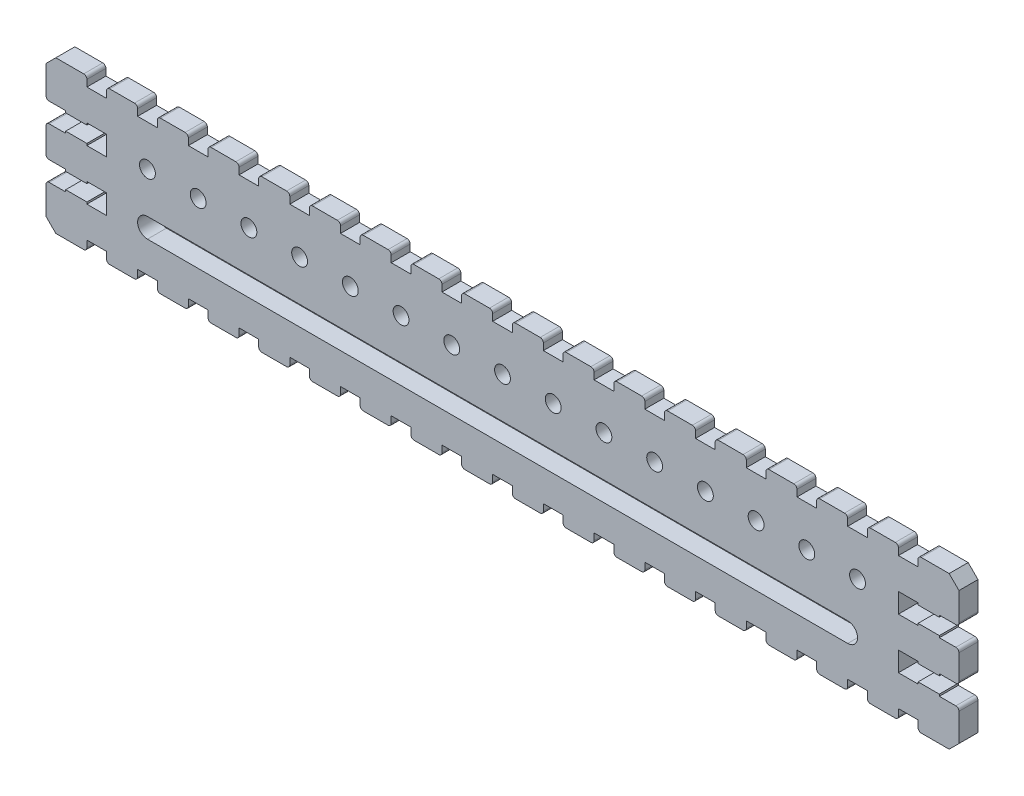
from build123d import *

# Parameters (mm, degrees)
SKETCH_1_R      = 1.25
EXTRUDE_1_DEPTH = 3


with BuildPart() as part:
    # 草图1 → 凸台-拉伸1 (new body)
    with BuildSketch(Plane.XY):
        with BuildLine():
            Line((8.341212166, 48.379842569), (12.741212166, 48.379842569))
            ThreePointArc((12.741212166, 48.379842569), (13.094765557, 48.23339596), (13.241212166, 47.879842569))
            Line((13.241212166, 47.879842569), (13.241212166, 46.829842569))
            Line((13.241212166, 46.829842569), (16.341212166, 46.829842569))
            Line((16.341212166, 46.829842569), (16.341212166, 47.879842569))
            ThreePointArc((16.341212166, 47.879842569), (16.487658775, 48.23339596), (16.841212166, 48.379842569))
            Line((16.841212166, 48.379842569), (20.741212166, 48.379842569))
            ThreePointArc((20.741212166, 48.379842569), (21.094765557, 48.23339596), (21.241212166, 47.879842569))
            Line((21.241212166, 47.879842569), (21.241212166, 46.829842569))
            Line((21.241212166, 46.829842569), (24.341212166, 46.829842569))
            Line((24.341212166, 46.829842569), (24.341212166, 47.879842569))
            ThreePointArc((24.341212166, 47.879842569), (24.487658775, 48.23339596), (24.841212166, 48.379842569))
            Line((24.841212166, 48.379842569), (28.741212166, 48.379842569))
            ThreePointArc((28.741212166, 48.379842569), (29.094765557, 48.23339596), (29.241212166, 47.879842569))
            Line((29.241212166, 47.879842569), (29.241212166, 46.829842569))
            Line((29.241212166, 46.829842569), (32.341212166, 46.829842569))
            Line((32.341212166, 46.829842569), (32.341212166, 47.879842569))
            ThreePointArc((32.341212166, 47.879842569), (32.487658775, 48.23339596), (32.841212166, 48.379842569))
            Line((32.841212166, 48.379842569), (36.741212166, 48.379842569))
            ThreePointArc((36.741212166, 48.379842569), (37.094765557, 48.23339596), (37.241212166, 47.879842569))
            Line((37.241212166, 47.879842569), (37.241212166, 46.829842569))
            Line((37.241212166, 46.829842569), (40.341212166, 46.829842569))
            Line((40.341212166, 46.829842569), (40.341212166, 47.879842569))
            ThreePointArc((40.341212166, 47.879842569), (40.487658775, 48.23339596), (40.841212166, 48.379842569))
            Line((40.841212166, 48.379842569), (44.741212166, 48.379842569))
            ThreePointArc((44.741212166, 48.379842569), (45.094765557, 48.23339596), (45.241212166, 47.879842569))
            Line((45.241212166, 47.879842569), (45.241212166, 46.829842569))
            Line((45.241212166, 46.829842569), (48.341212166, 46.829842569))
            Line((48.341212166, 46.829842569), (48.341212166, 47.879842569))
            ThreePointArc((48.341212166, 47.879842569), (48.487658775, 48.23339596), (48.841212166, 48.379842569))
            Line((48.841212166, 48.379842569), (52.741212166, 48.379842569))
            ThreePointArc((52.741212166, 48.379842569), (53.094765557, 48.23339596), (53.241212166, 47.879842569))
            Line((53.241212166, 47.879842569), (53.241212166, 46.829842569))
            Line((53.241212166, 46.829842569), (56.341212166, 46.829842569))
            Line((56.341212166, 46.829842569), (56.341212166, 47.879842569))
            ThreePointArc((56.341212166, 47.879842569), (56.487658775, 48.23339596), (56.841212166, 48.379842569))
            Line((56.841212166, 48.379842569), (60.741212166, 48.379842569))
            ThreePointArc((60.741212166, 48.379842569), (61.094765557, 48.23339596), (61.241212166, 47.879842569))
            Line((61.241212166, 47.879842569), (61.241212166, 46.829842569))
            Line((61.241212166, 46.829842569), (64.341212166, 46.829842569))
            Line((64.341212166, 46.829842569), (64.341212166, 47.879842569))
            ThreePointArc((64.341212166, 47.879842569), (64.487658775, 48.23339596), (64.841212166, 48.379842569))
            Line((64.841212166, 48.379842569), (68.741212166, 48.379842569))
            ThreePointArc((68.741212166, 48.379842569), (69.094765557, 48.23339596), (69.241212166, 47.879842569))
            Line((69.241212166, 47.879842569), (69.241212166, 46.829842569))
            Line((69.241212166, 46.829842569), (72.341212166, 46.829842569))
            Line((72.341212166, 46.829842569), (72.341212166, 47.879842569))
            ThreePointArc((72.341212166, 47.879842569), (72.487658775, 48.23339596), (72.841212166, 48.379842569))
            Line((72.841212166, 48.379842569), (76.741212166, 48.379842569))
            ThreePointArc((76.741212166, 48.379842569), (77.094765557, 48.23339596), (77.241212166, 47.879842569))
            Line((77.241212166, 47.879842569), (77.241212166, 46.829842569))
            Line((77.241212166, 46.829842569), (80.341212166, 46.829842569))
            Line((80.341212166, 46.829842569), (80.341212166, 47.879842569))
            ThreePointArc((80.341212166, 47.879842569), (80.487658775, 48.23339596), (80.841212166, 48.379842569))
            Line((80.841212166, 48.379842569), (84.741212166, 48.379842569))
            ThreePointArc((84.741212166, 48.379842569), (85.094765557, 48.23339596), (85.241212166, 47.879842569))
            Line((85.241212166, 47.879842569), (85.241212166, 46.829842569))
            Line((85.241212166, 46.829842569), (88.341212166, 46.829842569))
            Line((88.341212166, 46.829842569), (88.341212166, 47.879842569))
            ThreePointArc((88.341212166, 47.879842569), (88.487658775, 48.23339596), (88.841212166, 48.379842569))
            Line((88.841212166, 48.379842569), (92.741212166, 48.379842569))
            ThreePointArc((92.741212166, 48.379842569), (93.094765557, 48.23339596), (93.241212166, 47.879842569))
            Line((93.241212166, 47.879842569), (93.241212166, 46.829842569))
            Line((93.241212166, 46.829842569), (96.341212166, 46.829842569))
            Line((96.341212166, 46.829842569), (96.341212166, 47.879842569))
            ThreePointArc((96.341212166, 47.879842569), (96.487658775, 48.23339596), (96.841212166, 48.379842569))
            Line((96.841212166, 48.379842569), (100.741212166, 48.379842569))
            ThreePointArc((100.741212166, 48.379842569), (101.094765557, 48.23339596), (101.241212166, 47.879842569))
            Line((101.241212166, 47.879842569), (101.241212166, 46.829842569))
            Line((101.241212166, 46.829842569), (104.341212166, 46.829842569))
            Line((104.341212166, 46.829842569), (104.341212166, 47.879842569))
            ThreePointArc((104.341212166, 47.879842569), (104.487658775, 48.23339596), (104.841212166, 48.379842569))
            Line((104.841212166, 48.379842569), (108.741212166, 48.379842569))
            ThreePointArc((108.741212166, 48.379842569), (109.094765557, 48.23339596), (109.241212166, 47.879842569))
            Line((109.241212166, 47.879842569), (109.241212166, 46.829842569))
            Line((109.241212166, 46.829842569), (112.341212166, 46.829842569))
            Line((112.341212166, 46.829842569), (112.341212166, 47.879842569))
            ThreePointArc((112.341212166, 47.879842569), (112.487658775, 48.23339596), (112.841212166, 48.379842569))
            Line((112.841212166, 48.379842569), (116.741212166, 48.379842569))
            ThreePointArc((116.741212166, 48.379842569), (117.094765557, 48.23339596), (117.241212166, 47.879842569))
            Line((117.241212166, 47.879842569), (117.241212166, 46.829842569))
            Line((117.241212166, 46.829842569), (120.341212166, 46.829842569))
            Line((120.341212166, 46.829842569), (120.341212166, 47.879842569))
            ThreePointArc((120.341212166, 47.879842569), (120.487658775, 48.23339596), (120.841212166, 48.379842569))
            Line((120.841212166, 48.379842569), (124.741212166, 48.379842569))
            ThreePointArc((124.741212166, 48.379842569), (125.094765557, 48.23339596), (125.241212166, 47.879842569))
            Line((125.241212166, 47.879842569), (125.241212166, 46.829842569))
            Line((125.241212166, 46.829842569), (128.341212166, 46.829842569))
            Line((128.341212166, 46.829842569), (128.341212166, 47.879842569))
            ThreePointArc((128.341212166, 47.879842569), (128.487658775, 48.23339596), (128.841212166, 48.379842569))
            Line((128.841212166, 48.379842569), (132.741212166, 48.379842569))
            ThreePointArc((132.741212166, 48.379842569), (133.094765557, 48.23339596), (133.241212166, 47.879842569))
            Line((133.241212166, 47.879842569), (133.241212166, 46.829842569))
            Line((133.241212166, 46.829842569), (136.341212166, 46.829842569))
            Line((136.341212166, 46.829842569), (136.341212166, 47.879842569))
            ThreePointArc((136.341212166, 47.879842569), (136.487658775, 48.23339596), (136.841212166, 48.379842569))
            Line((136.841212166, 48.379842569), (140.741212166, 48.379842569))
            ThreePointArc((140.741212166, 48.379842569), (141.094765557, 48.23339596), (141.241212166, 47.879842569))
            Line((141.241212166, 47.879842569), (141.241212166, 46.829842569))
            Line((141.241212166, 46.829842569), (144.341212166, 46.829842569))
            Line((144.341212166, 46.829842569), (144.341212166, 47.879842569))
            ThreePointArc((144.341212166, 47.879842569), (144.487658775, 48.23339596), (144.841212166, 48.379842569))
            Line((144.841212166, 48.379842569), (149.241212166, 48.379842569))
            Line((149.241212166, 48.379842569), (150.791212166, 46.829842569))
            Line((150.791212166, 46.829842569), (150.791212166, 42.429842569))
            ThreePointArc((150.791212166, 42.429842569), (150.644765557, 42.076289178), (150.291212166, 41.929842569))
            Line((150.291212166, 41.929842569), (147.691212166, 41.929842569))
            Line((147.691212166, 41.929842569), (147.691212166, 41.629842569))
            Line((147.691212166, 41.629842569), (144.341212166, 41.629842569))
            Line((144.341212166, 41.629842569), (144.341212166, 41.929842569))
            Line((144.341212166, 41.929842569), (141.241212166, 41.929842569))
            Line((141.241212166, 41.929842569), (141.241212166, 38.829842569))
            Line((141.241212166, 38.829842569), (144.341212166, 38.829842569))
            Line((144.341212166, 38.829842569), (144.341212166, 39.129842569))
            Line((144.341212166, 39.129842569), (147.691212166, 39.129842569))
            Line((147.691212166, 39.129842569), (147.691212166, 38.829842569))
            Line((147.691212166, 38.829842569), (150.291212166, 38.829842569))
            ThreePointArc((150.291212166, 38.829842569), (150.644765557, 38.68339596), (150.791212166, 38.329842569))
            Line((150.791212166, 38.329842569), (150.791212166, 34.429842569))
            ThreePointArc((150.791212166, 34.429842569), (150.644765557, 34.076289178), (150.291212166, 33.929842569))
            Line((150.291212166, 33.929842569), (147.691212166, 33.929842569))
            Line((147.691212166, 33.929842569), (147.691212166, 33.629842569))
            Line((147.691212166, 33.629842569), (144.341212166, 33.629842569))
            Line((144.341212166, 33.629842569), (144.341212166, 33.929842569))
            Line((144.341212166, 33.929842569), (141.241212166, 33.929842569))
            Line((141.241212166, 33.929842569), (141.241212166, 30.829842569))
            Line((141.241212166, 30.829842569), (144.341212166, 30.829842569))
            Line((144.341212166, 30.829842569), (144.341212166, 31.129842569))
            Line((144.341212166, 31.129842569), (147.691212166, 31.129842569))
            Line((147.691212166, 31.129842569), (147.691212166, 30.829842569))
            Line((147.691212166, 30.829842569), (150.291212166, 30.829842569))
            ThreePointArc((150.291212166, 30.829842569), (150.644765557, 30.68339596), (150.791212166, 30.329842569))
            Line((150.791212166, 30.329842569), (150.791212166, 25.929842569))
            Line((150.791212166, 25.929842569), (149.241212166, 24.379842569))
            Line((149.241212166, 24.379842569), (144.841212166, 24.379842569))
            ThreePointArc((144.841212166, 24.379842569), (144.487658775, 24.526289178), (144.341212166, 24.879842569))
            Line((144.341212166, 24.879842569), (144.341212166, 25.929842569))
            Line((144.341212166, 25.929842569), (141.241212166, 25.929842569))
            Line((141.241212166, 25.929842569), (141.241212166, 24.879842569))
            ThreePointArc((141.241212166, 24.879842569), (141.094765557, 24.526289178), (140.741212166, 24.379842569))
            Line((140.741212166, 24.379842569), (136.841212166, 24.379842569))
            ThreePointArc((136.841212166, 24.379842569), (136.487658775, 24.526289178), (136.341212166, 24.879842569))
            Line((136.341212166, 24.879842569), (136.341212166, 25.929842569))
            Line((136.341212166, 25.929842569), (133.241212166, 25.929842569))
            Line((133.241212166, 25.929842569), (133.241212166, 24.879842569))
            ThreePointArc((133.241212166, 24.879842569), (133.094765557, 24.526289178), (132.741212166, 24.379842569))
            Line((132.741212166, 24.379842569), (128.841212166, 24.379842569))
            ThreePointArc((128.841212166, 24.379842569), (128.487658775, 24.526289178), (128.341212166, 24.879842569))
            Line((128.341212166, 24.879842569), (128.341212166, 25.929842569))
            Line((128.341212166, 25.929842569), (125.241212166, 25.929842569))
            Line((125.241212166, 25.929842569), (125.241212166, 24.879842569))
            ThreePointArc((125.241212166, 24.879842569), (125.094765557, 24.526289178), (124.741212166, 24.379842569))
            Line((124.741212166, 24.379842569), (120.841212166, 24.379842569))
            ThreePointArc((120.841212166, 24.379842569), (120.487658775, 24.526289178), (120.341212166, 24.879842569))
            Line((120.341212166, 24.879842569), (120.341212166, 25.929842569))
            Line((120.341212166, 25.929842569), (117.241212166, 25.929842569))
            Line((117.241212166, 25.929842569), (117.241212166, 24.879842569))
            ThreePointArc((117.241212166, 24.879842569), (117.094765557, 24.526289178), (116.741212166, 24.379842569))
            Line((116.741212166, 24.379842569), (112.841212166, 24.379842569))
            ThreePointArc((112.841212166, 24.379842569), (112.487658775, 24.526289178), (112.341212166, 24.879842569))
            Line((112.341212166, 24.879842569), (112.341212166, 25.929842569))
            Line((112.341212166, 25.929842569), (109.241212166, 25.929842569))
            Line((109.241212166, 25.929842569), (109.241212166, 24.879842569))
            ThreePointArc((109.241212166, 24.879842569), (109.094765557, 24.526289178), (108.741212166, 24.379842569))
            Line((108.741212166, 24.379842569), (104.841212166, 24.379842569))
            ThreePointArc((104.841212166, 24.379842569), (104.487658775, 24.526289178), (104.341212166, 24.879842569))
            Line((104.341212166, 24.879842569), (104.341212166, 25.929842569))
            Line((104.341212166, 25.929842569), (101.241212166, 25.929842569))
            Line((101.241212166, 25.929842569), (101.241212166, 24.879842569))
            ThreePointArc((101.241212166, 24.879842569), (101.094765557, 24.526289178), (100.741212166, 24.379842569))
            Line((100.741212166, 24.379842569), (96.841212166, 24.379842569))
            ThreePointArc((96.841212166, 24.379842569), (96.487658775, 24.526289178), (96.341212166, 24.879842569))
            Line((96.341212166, 24.879842569), (96.341212166, 25.929842569))
            Line((96.341212166, 25.929842569), (93.241212166, 25.929842569))
            Line((93.241212166, 25.929842569), (93.241212166, 24.879842569))
            ThreePointArc((93.241212166, 24.879842569), (93.094765557, 24.526289178), (92.741212166, 24.379842569))
            Line((92.741212166, 24.379842569), (88.841212166, 24.379842569))
            ThreePointArc((88.841212166, 24.379842569), (88.487658775, 24.526289178), (88.341212166, 24.879842569))
            Line((88.341212166, 24.879842569), (88.341212166, 25.929842569))
            Line((88.341212166, 25.929842569), (85.241212166, 25.929842569))
            Line((85.241212166, 25.929842569), (85.241212166, 24.879842569))
            ThreePointArc((85.241212166, 24.879842569), (85.094765557, 24.526289178), (84.741212166, 24.379842569))
            Line((84.741212166, 24.379842569), (80.841212166, 24.379842569))
            ThreePointArc((80.841212166, 24.379842569), (80.487658775, 24.526289178), (80.341212166, 24.879842569))
            Line((80.341212166, 24.879842569), (80.341212166, 25.929842569))
            Line((80.341212166, 25.929842569), (77.241212166, 25.929842569))
            Line((77.241212166, 25.929842569), (77.241212166, 24.879842569))
            ThreePointArc((77.241212166, 24.879842569), (77.094765557, 24.526289178), (76.741212166, 24.379842569))
            Line((76.741212166, 24.379842569), (72.841212166, 24.379842569))
            ThreePointArc((72.841212166, 24.379842569), (72.487658775, 24.526289178), (72.341212166, 24.879842569))
            Line((72.341212166, 24.879842569), (72.341212166, 25.929842569))
            Line((72.341212166, 25.929842569), (69.241212166, 25.929842569))
            Line((69.241212166, 25.929842569), (69.241212166, 24.879842569))
            ThreePointArc((69.241212166, 24.879842569), (69.094765557, 24.526289178), (68.741212166, 24.379842569))
            Line((68.741212166, 24.379842569), (64.841212166, 24.379842569))
            ThreePointArc((64.841212166, 24.379842569), (64.487658775, 24.526289178), (64.341212166, 24.879842569))
            Line((64.341212166, 24.879842569), (64.341212166, 25.929842569))
            Line((64.341212166, 25.929842569), (61.241212166, 25.929842569))
            Line((61.241212166, 25.929842569), (61.241212166, 24.879842569))
            ThreePointArc((61.241212166, 24.879842569), (61.094765557, 24.526289178), (60.741212166, 24.379842569))
            Line((60.741212166, 24.379842569), (56.841212166, 24.379842569))
            ThreePointArc((56.841212166, 24.379842569), (56.487658775, 24.526289178), (56.341212166, 24.879842569))
            Line((56.341212166, 24.879842569), (56.341212166, 25.929842569))
            Line((56.341212166, 25.929842569), (53.241212166, 25.929842569))
            Line((53.241212166, 25.929842569), (53.241212166, 24.879842569))
            ThreePointArc((53.241212166, 24.879842569), (53.094765557, 24.526289178), (52.741212166, 24.379842569))
            Line((52.741212166, 24.379842569), (48.841212166, 24.379842569))
            ThreePointArc((48.841212166, 24.379842569), (48.487658775, 24.526289178), (48.341212166, 24.879842569))
            Line((48.341212166, 24.879842569), (48.341212166, 25.929842569))
            Line((48.341212166, 25.929842569), (45.241212166, 25.929842569))
            Line((45.241212166, 25.929842569), (45.241212166, 24.879842569))
            ThreePointArc((45.241212166, 24.879842569), (45.094765557, 24.526289178), (44.741212166, 24.379842569))
            Line((44.741212166, 24.379842569), (40.841212166, 24.379842569))
            ThreePointArc((40.841212166, 24.379842569), (40.487658775, 24.526289178), (40.341212166, 24.879842569))
            Line((40.341212166, 24.879842569), (40.341212166, 25.929842569))
            Line((40.341212166, 25.929842569), (37.241212166, 25.929842569))
            Line((37.241212166, 25.929842569), (37.241212166, 24.879842569))
            ThreePointArc((37.241212166, 24.879842569), (37.094765557, 24.526289178), (36.741212166, 24.379842569))
            Line((36.741212166, 24.379842569), (32.841212166, 24.379842569))
            ThreePointArc((32.841212166, 24.379842569), (32.487658775, 24.526289178), (32.341212166, 24.879842569))
            Line((32.341212166, 24.879842569), (32.341212166, 25.929842569))
            Line((32.341212166, 25.929842569), (29.241212166, 25.929842569))
            Line((29.241212166, 25.929842569), (29.241212166, 24.879842569))
            ThreePointArc((29.241212166, 24.879842569), (29.094765557, 24.526289178), (28.741212166, 24.379842569))
            Line((28.741212166, 24.379842569), (24.841212166, 24.379842569))
            ThreePointArc((24.841212166, 24.379842569), (24.487658775, 24.526289178), (24.341212166, 24.879842569))
            Line((24.341212166, 24.879842569), (24.341212166, 25.929842569))
            Line((24.341212166, 25.929842569), (21.241212166, 25.929842569))
            Line((21.241212166, 25.929842569), (21.241212166, 24.879842569))
            ThreePointArc((21.241212166, 24.879842569), (21.094765557, 24.526289178), (20.741212166, 24.379842569))
            Line((20.741212166, 24.379842569), (16.841212166, 24.379842569))
            ThreePointArc((16.841212166, 24.379842569), (16.487658775, 24.526289178), (16.341212166, 24.879842569))
            Line((16.341212166, 24.879842569), (16.341212166, 25.929842569))
            Line((16.341212166, 25.929842569), (13.241212166, 25.929842569))
            Line((13.241212166, 25.929842569), (13.241212166, 24.879842569))
            ThreePointArc((13.241212166, 24.879842569), (13.094765557, 24.526289178), (12.741212166, 24.379842569))
            Line((12.741212166, 24.379842569), (8.341212166, 24.379842569))
            Line((8.341212166, 24.379842569), (6.791212166, 25.929842569))
            Line((6.791212166, 25.929842569), (6.791212166, 30.329842569))
            ThreePointArc((6.791212166, 30.329842569), (6.937658775, 30.68339596), (7.291212166, 30.829842569))
            Line((7.291212166, 30.829842569), (9.891212166, 30.829842569))
            Line((9.891212166, 30.829842569), (9.891212166, 31.129842569))
            Line((9.891212166, 31.129842569), (13.241212166, 31.129842569))
            Line((13.241212166, 31.129842569), (13.241212166, 30.829842569))
            Line((13.241212166, 30.829842569), (16.341212166, 30.829842569))
            Line((16.341212166, 30.829842569), (16.341212166, 33.929842569))
            Line((16.341212166, 33.929842569), (13.241212166, 33.929842569))
            Line((13.241212166, 33.929842569), (13.241212166, 33.629842569))
            Line((13.241212166, 33.629842569), (9.891212166, 33.629842569))
            Line((9.891212166, 33.629842569), (9.891212166, 33.929842569))
            Line((9.891212166, 33.929842569), (7.291212166, 33.929842569))
            ThreePointArc((7.291212166, 33.929842569), (6.937658775, 34.076289178), (6.791212166, 34.429842569))
            Line((6.791212166, 34.429842569), (6.791212166, 38.329842569))
            ThreePointArc((6.791212166, 38.329842569), (6.937658775, 38.68339596), (7.291212166, 38.829842569))
            Line((7.291212166, 38.829842569), (9.891212166, 38.829842569))
            Line((9.891212166, 38.829842569), (9.891212166, 39.129842569))
            Line((9.891212166, 39.129842569), (13.241212166, 39.129842569))
            Line((13.241212166, 39.129842569), (13.241212166, 38.829842569))
            Line((13.241212166, 38.829842569), (16.341212166, 38.829842569))
            Line((16.341212166, 38.829842569), (16.341212166, 41.929842569))
            Line((16.341212166, 41.929842569), (13.241212166, 41.929842569))
            Line((13.241212166, 41.929842569), (13.241212166, 41.629842569))
            Line((13.241212166, 41.629842569), (9.891212166, 41.629842569))
            Line((9.891212166, 41.629842569), (9.891212166, 41.929842569))
            Line((9.891212166, 41.929842569), (7.291212166, 41.929842569))
            ThreePointArc((7.291212166, 41.929842569), (6.937658775, 42.076289178), (6.791212166, 42.429842569))
            Line((6.791212166, 42.429842569), (6.791212166, 46.829842569))
            Line((6.791212166, 46.829842569), (8.341212166, 48.379842569))
        make_face()
        with Locations((22.791212166, 40.379842569)):
            Circle(SKETCH_1_R, mode=Mode.SUBTRACT)
        with Locations((30.791212166, 40.379842569)):
            Circle(SKETCH_1_R, mode=Mode.SUBTRACT)
        with Locations((38.791212166, 40.379842569)):
            Circle(SKETCH_1_R, mode=Mode.SUBTRACT)
        with Locations((46.791212166, 40.379842569)):
            Circle(SKETCH_1_R, mode=Mode.SUBTRACT)
        with Locations((54.791212166, 40.379842569)):
            Circle(SKETCH_1_R, mode=Mode.SUBTRACT)
        with Locations((62.791212166, 40.379842569)):
            Circle(SKETCH_1_R, mode=Mode.SUBTRACT)
        with Locations((70.791212166, 40.379842569)):
            Circle(SKETCH_1_R, mode=Mode.SUBTRACT)
        with Locations((78.791212166, 40.379842569)):
            Circle(SKETCH_1_R, mode=Mode.SUBTRACT)
        with Locations((86.791212166, 40.379842569)):
            Circle(SKETCH_1_R, mode=Mode.SUBTRACT)
        with Locations((94.791212166, 40.379842569)):
            Circle(SKETCH_1_R, mode=Mode.SUBTRACT)
        with Locations((102.791212166, 40.379842569)):
            Circle(SKETCH_1_R, mode=Mode.SUBTRACT)
        with Locations((110.791212166, 40.379842569)):
            Circle(SKETCH_1_R, mode=Mode.SUBTRACT)
        with Locations((118.791212166, 40.379842569)):
            Circle(SKETCH_1_R, mode=Mode.SUBTRACT)
        with Locations((126.791212166, 40.379842569)):
            Circle(SKETCH_1_R, mode=Mode.SUBTRACT)
        with Locations((134.791212166, 40.379842569)):
            Circle(SKETCH_1_R, mode=Mode.SUBTRACT)
        with BuildLine():
            Line((133.241212166, 33.929842569), (22.791212166, 33.929842569))
            ThreePointArc((22.791212166, 33.929842569), (21.241212166, 32.379842569), (22.791212166, 30.829842569))
            Line((22.791212166, 30.829842569), (133.241212166, 30.829842569))
            ThreePointArc((133.241212166, 30.829842569), (134.791212166, 32.379842569), (133.241212166, 33.929842569))
        make_face(mode=Mode.SUBTRACT)
    extrude(amount=EXTRUDE_1_DEPTH)


solid = part.part
